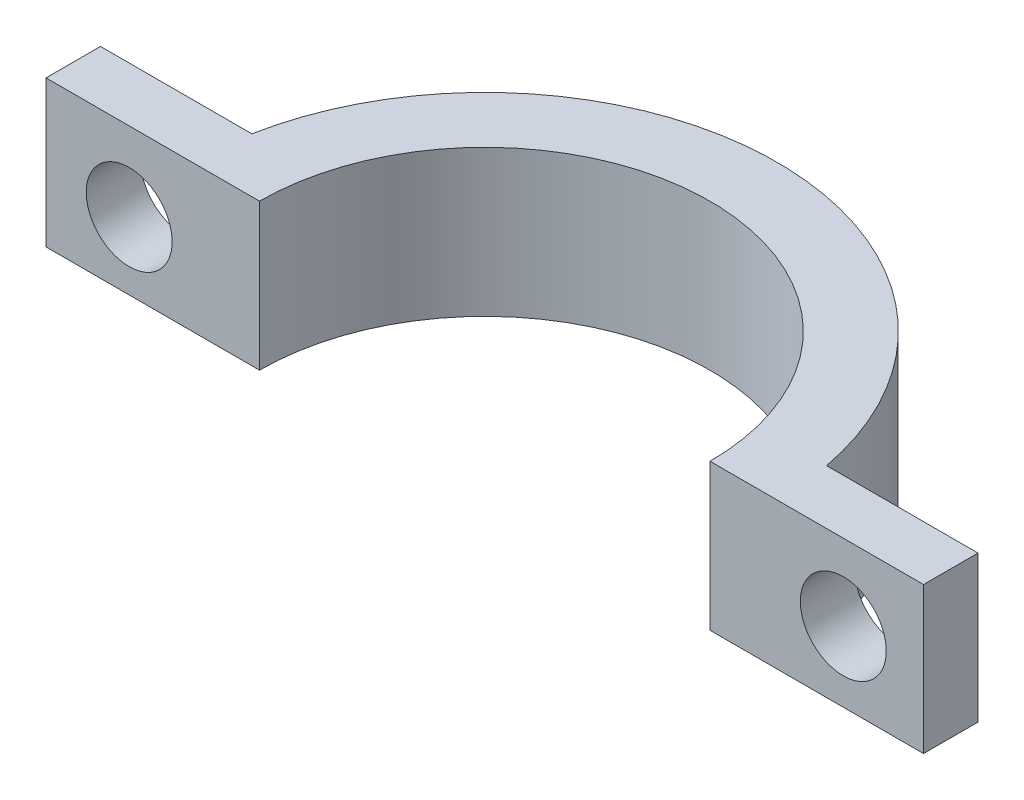
from build123d import *

# Parameters (mm, degrees)
EXTRUDE_1_DEPTH     = 13
SKETCH_3_R          = 3.81432267
CUT_EXTRUDE_3_DEPTH = 13


with BuildPart() as part:
    # Эскиз1 → Бобышка-Вытянуть1 (new body)
    with BuildSketch(Plane(origin=(0, 0, 0), x_dir=(1, 0, 0), z_dir=(0, 1, 0))):
        with BuildLine():
            Line((-38.957311272, 6.682533514), (-38.957311272, 1.845513979))
            Line((-38.957311272, 1.845513979), (-20, 1.845513979))
            ThreePointArc((-20, 1.845513979), (0, 21.845513979), (20, 1.845513979))
            Line((20, 1.845513979), (38.957311272, 1.845513979))
            Line((38.957311272, 1.845513979), (38.957311272, 6.682533514))
            Line((38.957311272, 6.682533514), (26, 6.682533514))
            Line((26, 6.682533514), (25.515318536, 6.682533514))
            ThreePointArc((25.515318536, 6.682533514), (0, 27.815270196), (-25.515318536, 6.682533514))
            Line((-25.515318536, 6.682533514), (-26, 6.682533514))
            Line((-26, 6.682533514), (-38.957311272, 6.682533514))
        make_face()
    extrude(amount=EXTRUDE_1_DEPTH)

    # Эскиз3 → Вырез-Вытянуть3 (cut)
    with BuildSketch(Plane(origin=(0, 0, -6.682533514), x_dir=(-1, 0, 0), z_dir=(0, 0, -1))):
        with Locations((31.571414086, 5.993746115)):
            Circle(SKETCH_3_R)
        with Locations((-31.834355238, 6.230792633)):
            Circle(SKETCH_3_R)
    extrude(amount=-CUT_EXTRUDE_3_DEPTH, mode=Mode.SUBTRACT)


solid = part.part
